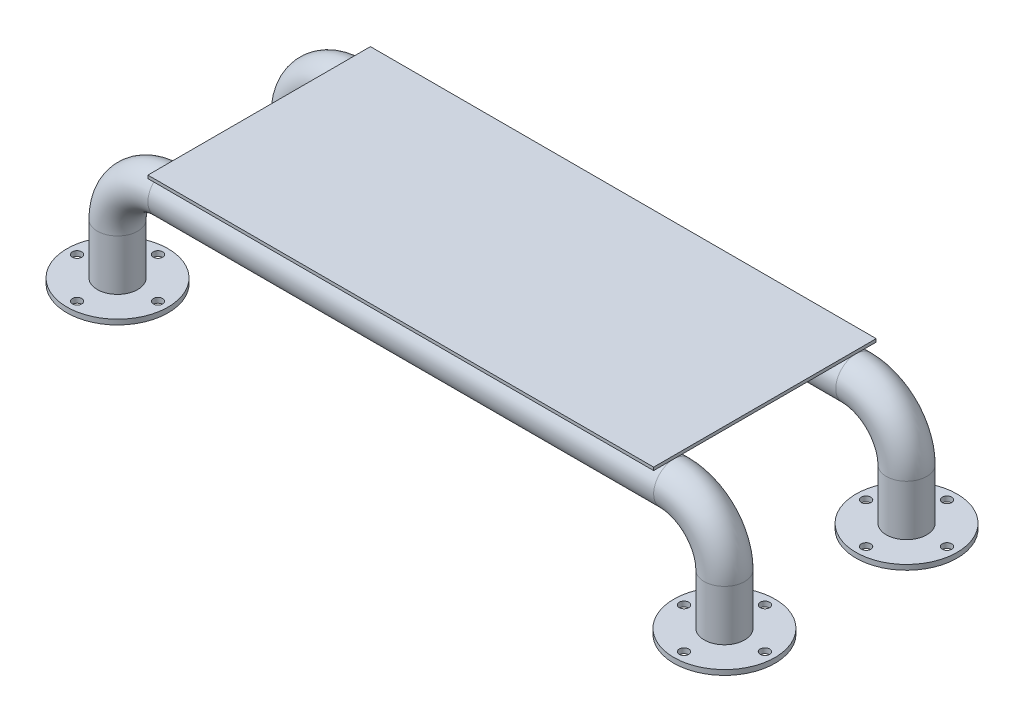
from build123d import *

# Parameters (mm, degrees)
SKETCH2_R                       = 20
SKETCH4_R                       = 20
SKETCH5_R                       = 50
BOSS_EXTRUDE1_DEPTH             = 5
BOSS_EXTRUDE2_REACH             = 132
SKETCH8_R                       = 20
BOSS_EXTRUDE2_DIRECTION_2_REACH = 152
SKETCH10_W                      = 500
SKETCH10_H                      = 220
BOSS_EXTRUDE3_DEPTH             = 3
SKETCH11_R                      = 4.675667077
CUT_EXTRUDE1_DEPTH              = 5


with BuildPart() as part:
    # Sweep1: sweep along a path in Sketch1
    with BuildLine(Plane.XY) as sweep1_path:
        Line((-300, -100), (-300, -50))
        ThreePointArc((-300, -50), (-285.355339059, -14.644660941), (-250, 0))
        Line((-250, 0), (250, 0))
        ThreePointArc((250, 0), (285.355339059, -14.644660941), (300, -50))
        Line((300, -50), (300, -100))
    # Sketch2 → Sweep1 (sweep)
    with BuildSketch(Plane(origin=(0, 0, 0), x_dir=(0, 0, -1), z_dir=(1, 0, 0))):
        Circle(SKETCH2_R)
    sweep(path=sweep1_path.line)



with BuildPart() as body_2:
    # Sweep2: sweep along a path in Sketch3
    with BuildLine(Plane.XY.offset(180)) as sweep2_path:
        Line((-300, -100), (-300, -50))
        ThreePointArc((-300, -50), (-285.355339059, -14.644660941), (-250, 0))
        Line((-250, 0), (250, 0))
        ThreePointArc((250, 0), (285.355339059, -14.644660941), (300, -50))
        Line((300, -50), (300, -100))
    # Sketch4 → Sweep2 (sweep)
    with BuildSketch(Plane(origin=(0, 0, 0), x_dir=(0, 0, -1), z_dir=(1, 0, 0))):
        with Locations((-180, 0)):
            Circle(SKETCH4_R)
    sweep(path=sweep2_path.line)


with BuildPart() as part_1:
    add(part.part)

    add(body_2.part)  # Boss-Extrude1 merges body 2
    # Sketch5 → Boss-Extrude1 (add)
    with BuildSketch(Plane.XZ.offset(100)):
        with Locations((-300, 180)):
            Circle(SKETCH5_R)
        with Locations((-300, 0)):
            Circle(SKETCH5_R)
        with Locations((300, 0)):
            Circle(SKETCH5_R)
        with Locations((300, 180)):
            Circle(SKETCH5_R)
    extrude(amount=BOSS_EXTRUDE1_DEPTH)

    # Sketch8 → Boss-Extrude2 (add, up to next)
    with BuildSketch(Plane.XY.offset(100), mode=Mode.PRIVATE) as boss_extrude2_sk1:
        with Locations((-100, 0)):
            Circle(SKETCH8_R)
    boss_extrude2_tool1 = extrude(boss_extrude2_sk1.sketch, amount=BOSS_EXTRUDE2_REACH, mode=Mode.PRIVATE) - part_1.part
    add(boss_extrude2_tool1.solids().sort_by_distance((-100, 0, 100))[0])
    # Sketch8 → Boss-Extrude2 (add, up to next)
    with BuildSketch(Plane.XY.offset(100), mode=Mode.PRIVATE) as boss_extrude2_sk2:
        with Locations((100, 0)):
            Circle(SKETCH8_R)
    boss_extrude2_tool2 = extrude(boss_extrude2_sk2.sketch, amount=BOSS_EXTRUDE2_REACH, mode=Mode.PRIVATE) - part_1.part
    add(boss_extrude2_tool2.solids().sort_by_distance((100, 0, 100))[0])

    # Sketch8 → Boss-Extrude2 direction 2 (add, up to next)
    with BuildSketch(Plane.XY.offset(100), mode=Mode.PRIVATE) as boss_extrude2_direction_2_sk1:
        with Locations((-100, 0)):
            Circle(SKETCH8_R)
    boss_extrude2_direction_2_tool1 = extrude(boss_extrude2_direction_2_sk1.sketch, amount=-BOSS_EXTRUDE2_DIRECTION_2_REACH, mode=Mode.PRIVATE) - part_1.part
    add(boss_extrude2_direction_2_tool1.solids().sort_by_distance((-100, 0, 100))[0])
    # Sketch8 → Boss-Extrude2 direction 2 (add, up to next)
    with BuildSketch(Plane.XY.offset(100), mode=Mode.PRIVATE) as boss_extrude2_direction_2_sk2:
        with Locations((100, 0)):
            Circle(SKETCH8_R)
    boss_extrude2_direction_2_tool2 = extrude(boss_extrude2_direction_2_sk2.sketch, amount=-BOSS_EXTRUDE2_DIRECTION_2_REACH, mode=Mode.PRIVATE) - part_1.part
    add(boss_extrude2_direction_2_tool2.solids().sort_by_distance((100, 0, 100))[0])

    # Sketch11 → Cut-Extrude1 (cut)
    with BuildSketch(Plane.XZ.offset(105)):
        with Locations((-300, 220)):
            Circle(SKETCH11_R)
        with Locations((-260, 180)):
            Circle(SKETCH11_R)
        with Locations((-300, 140)):
            Circle(SKETCH11_R)
        with Locations((-340, 180)):
            Circle(SKETCH11_R)
        with Locations((260, 180)):
            Circle(SKETCH11_R)
        with Locations((300, 140)):
            Circle(SKETCH11_R)
        with Locations((340, 180)):
            Circle(SKETCH11_R)
        with Locations((300, 220)):
            Circle(SKETCH11_R)
        with Locations((-340, 0)):
            Circle(SKETCH11_R)
        with Locations((-300, 40)):
            Circle(SKETCH11_R)
        with Locations((-260, 0)):
            Circle(SKETCH11_R)
        with Locations((-300, -40)):
            Circle(SKETCH11_R)
        with Locations((300, -40)):
            Circle(SKETCH11_R)
        with Locations((340, 0)):
            Circle(SKETCH11_R)
        with Locations((300, 40)):
            Circle(SKETCH11_R)
        with Locations((260, 0)):
            Circle(SKETCH11_R)
    extrude(amount=-CUT_EXTRUDE1_DEPTH, mode=Mode.SUBTRACT)


with BuildPart() as body_2_2:
    # Sketch10 → Boss-Extrude3 (new body)
    with BuildSketch(Plane(origin=(0, 20, 0), x_dir=(1, 0, 0), z_dir=(0, 1, 0))):
        with Locations((0, -90)):
            Rectangle(SKETCH10_W, SKETCH10_H)
    extrude(amount=BOSS_EXTRUDE3_DEPTH)


solid = Compound([part_1.part, body_2_2.part])
